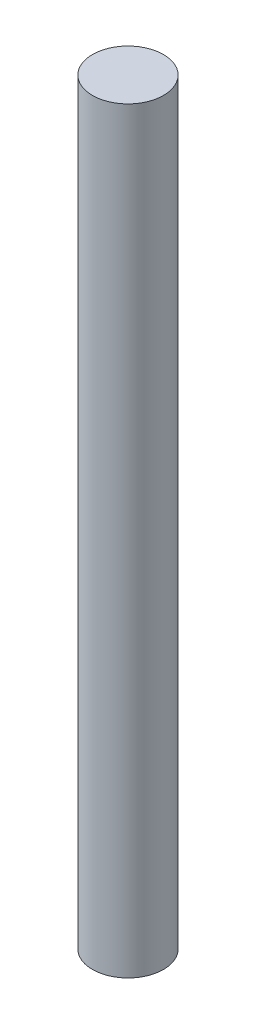
from build123d import *

# Parameters (mm, degrees)
SKETCH1_R           = 4.7625
BOSS_EXTRUDE1_DEPTH = 50.8


with BuildPart() as part:
    # Sketch1 → Boss-Extrude1 (new body, symmetric)
    with BuildSketch(Plane(origin=(0, 0, 0), x_dir=(1, 0, 0), z_dir=(0, 1, 0))):
        Circle(SKETCH1_R)
    extrude(amount=BOSS_EXTRUDE1_DEPTH, both=True)


solid = part.part
